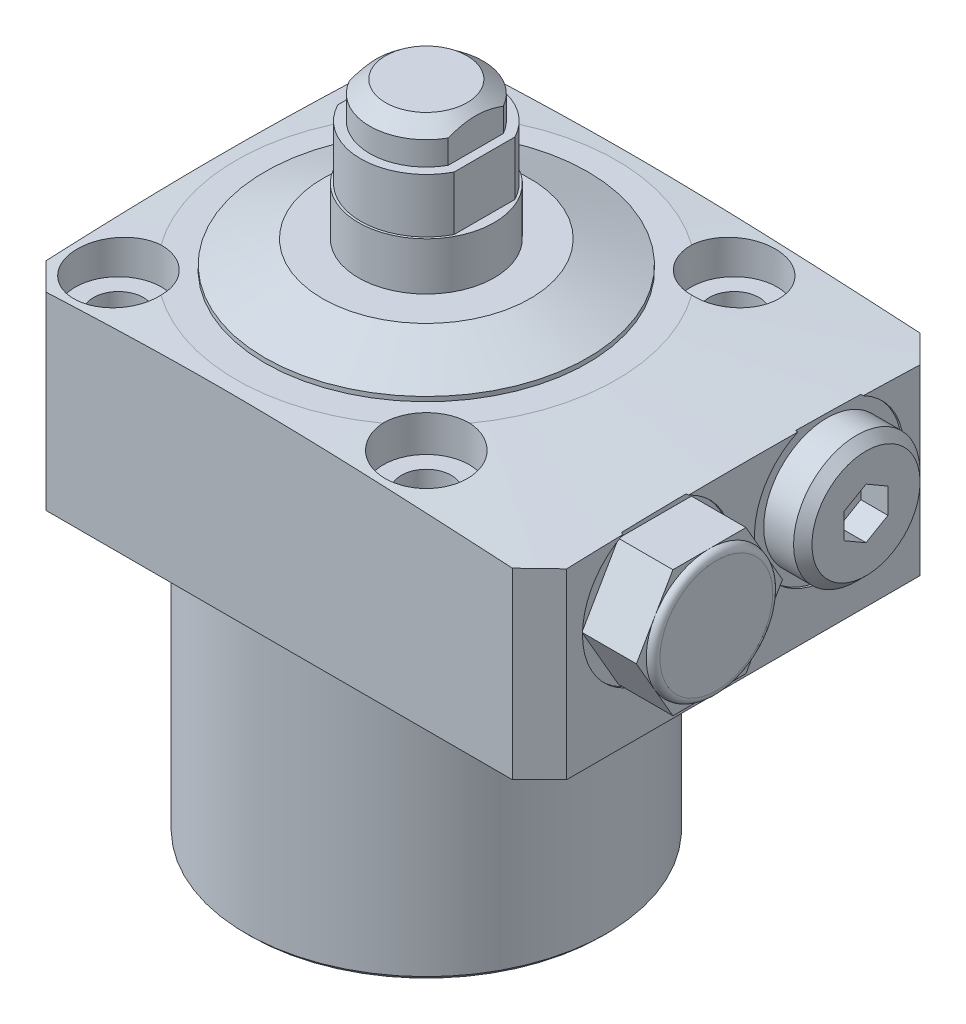
from build123d import *

# Parameters (mm, degrees)
SKETCH2_OUTSIDE_W          = 132.276
SKETCH2_OUTSIDE_H          = 132.276
SKETCH2_OUTSIDE_W_2        = 57.5
SKETCH2_OUTSIDE_H_2        = 45
CUT_EXTRUDE1_DEPTH         = 55
CHAMFER2_SIZE              = 3
CHAMFER1_SIZE              = 1.3714599
CHAMFER1_SIZE2             = 1.754126178
SKETCH5_W                  = 1.79
SKETCH5_H                  = 3.988
CUT_EXTRUDE2_DEPTH         = 23.5
CUT_EXTRUDE2_DEPTH_BACK    = 23.5
SKETCH6_W                  = 1.075
SKETCH6_H                  = 5.98
CUT_EXTRUDE3_DEPTH         = 23.5
CUT_EXTRUDE3_DEPTH_BACK    = 23.5
SKETCH10_R                 = 4.75
CUT_EXTRUDE4_DEPTH         = 4
F_5_5_5_5_DIAMETER_HOLE1_D = 5.5
CIRPATTERN1_COUNT          = 4
CUT_EXTRUDE5_DEPTH         = 3
LPATTERN1_COUNT            = 2
LPATTERN1_PITCH            = 19
SKETCH18_R                 = 1.5
LPATTERN2_COUNT            = 2
LPATTERN2_PITCH            = 19
CHAMFER3_SIZE              = 0.5
FILLET1_R                  = 0.5
BOSS_EXTRUDE2_DEPTH        = 6.78


with BuildPart() as part:
    # Sketch1 → Revolve1 (revolve)
    with BuildSketch(Plane.XY, mode=Mode.PRIVATE) as revolve1_sk:
        Polygon((-19.925, 0), (-50, 0), (-50, 19.472122454), (-21, 21.5), (0, 21.5), (0, -32.5), (-19.925, -32.5), align=None)
    revolve(revolve1_sk.sketch.rotate(Axis((0, 0, 0), (0, -1, 0)), 270), axis=Axis((0, 0, 0), (0, -1, 0)))  # turned: the seam where the file's is

    # Sketch2 outside → Cut-Extrude1 (cut, through all)
    with BuildSketch(Plane(origin=(0, 21.5, 0), x_dir=(1, 0, 0), z_dir=(0, 1, 0))):
        Rectangle(SKETCH2_OUTSIDE_W, SKETCH2_OUTSIDE_H)
        with Locations((6.25, 0)):
            Rectangle(SKETCH2_OUTSIDE_W_2, SKETCH2_OUTSIDE_H_2, mode=Mode.SUBTRACT)
    extrude(amount=-CUT_EXTRUDE1_DEPTH, mode=Mode.SUBTRACT)

    # Chamfer2
    chamfer2_edges = [part.edges().sort_by_distance(p)[0] for p in [
        (-22.5, 10.37170276, -22.5),
        (35, 10.029463905, -22.5),
        (35, 10.029463905, 22.5),
        (-22.5, 10.37170276, 22.5),
    ]]
    chamfer(chamfer2_edges, length=CHAMFER2_SIZE)

    # Sketch4 → Revolve2 (revolve)
    with BuildSketch(Plane.XY, mode=Mode.PRIVATE) as revolve2_sk:
        Polygon((0, 39.75), (-6.25, 39.75), (-6.25, 35.762), (-7.25, 35.762), (-7.25, 29.782), (-7.5, 29.782), (-7.5, 21.5), (0, 21.5), align=None)
    revolve(revolve2_sk.sketch.rotate(Axis((0, 0, 0), (0, 1, 0)), 270), axis=Axis((0, 0, 0), (0, 1, 0)))  # turned: the seam where the file's is

    # Chamfer1
    chamfer1_edges = [part.edges().sort_by_distance(p)[0] for p in [
        (0, 39.75, 6.25),
    ]]
    chamfer1_side = [part.faces().sort_by_distance(p)[0] for p in [
        (0, 37.756, 6.25),
    ]]
    chamfer(chamfer1_edges, length=CHAMFER1_SIZE, length2=CHAMFER1_SIZE2, reference=chamfer1_side[0])

    # Sketch5 → Cut-Extrude2 (cut, two sides)
    with BuildSketch(Plane.XY) as cut_extrude2_sk:
        with Locations((-6.355, 37.756)):
            Rectangle(SKETCH5_W, SKETCH5_H)
        with Locations((6.355, 37.756)):
            Rectangle(SKETCH5_W, SKETCH5_H)
    extrude(amount=CUT_EXTRUDE2_DEPTH, mode=Mode.SUBTRACT)
    extrude(cut_extrude2_sk.sketch, amount=-CUT_EXTRUDE2_DEPTH_BACK, mode=Mode.SUBTRACT)

    # Sketch6 → Cut-Extrude3 (cut, two sides)
    with BuildSketch(Plane.XY) as cut_extrude3_sk:
        with Locations((-6.9625, 32.772)):
            Rectangle(SKETCH6_W, SKETCH6_H)
        with Locations((6.9625, 32.772)):
            Rectangle(SKETCH6_W, SKETCH6_H)
    extrude(amount=CUT_EXTRUDE3_DEPTH, mode=Mode.SUBTRACT)
    extrude(cut_extrude3_sk.sketch, amount=-CUT_EXTRUDE3_DEPTH_BACK, mode=Mode.SUBTRACT)

    # Sketch10 → Cut-Extrude4 (cut)
    with BuildSketch(Plane(origin=(0, 21.5, 0), x_dir=(1, 0, 0), z_dir=(0, 1, 0))):
        with Locations(Location((-17, 17, 0), (0, 0, 269.316686409))):  # turned: the seam where the file's is
            Circle(SKETCH10_R)
    cut_extrude4 = extrude(amount=-CUT_EXTRUDE4_DEPTH, mode=Mode.SUBTRACT)

    # Ø5.5 (5.5) Diameter Hole1 (through all)
    with Locations(Plane(origin=(-17, 17.5, -17), x_dir=(0, 0, 1), z_dir=(0, 1, 0))):
        with Locations((0, 0)):
            f_5_5_5_5_diameter_hole1 = Hole(F_5_5_5_5_DIAMETER_HOLE1_D / 2)

    # CirPattern1: Cut-Extrude4, Ø5.5 (5.5) Diameter Hole1 ×4 about axis
    cirpattern1_axis = Axis((0, 0, 0), (0, 1, 0))
    add([cut_extrude4.rotate(cirpattern1_axis, i * 360 / CIRPATTERN1_COUNT) for i in range(1, CIRPATTERN1_COUNT)], mode=Mode.SUBTRACT)
    add([f_5_5_5_5_diameter_hole1.rotate(cirpattern1_axis, i * 360 / CIRPATTERN1_COUNT) for i in range(1, CIRPATTERN1_COUNT)], mode=Mode.SUBTRACT)

    # Sketch12 → Cut-Revolve2 (revolve, cut)
    with BuildSketch(Plane.XY.offset(-9.5), mode=Mode.PRIVATE) as cut_revolve2_sk:
        Polygon((35, 21.255), (34.75, 21.255), (34.75, 17.953), (34.2166, 17.4196), (24.1836, 17.4196), (21.528036408, 13), (35, 13), align=None)
    cut_revolve2 = revolve(cut_revolve2_sk.sketch.rotate(Axis((17.95729386, 13, -9.5), (1, 0, 0)), 90), axis=Axis((17.95729386, 13, -9.5), (1, 0, 0)), mode=Mode.SUBTRACT)  # turned: the seam where the file's is

    # Sketch13 → Revolve3 (revolve)
    with BuildSketch(Plane.XY.offset(-9.5), mode=Mode.PRIVATE) as revolve3_sk:
        Polygon((34.75, 19.985), (38.045, 19.985), (39.06, 18.97), (39.06, 13), (34.75, 13), align=None)
    revolve(revolve3_sk.sketch.rotate(Axis((10.466346838, 13, -9.5), (1, 0, 0)), 90), axis=Axis((10.466346838, 13, -9.5), (1, 0, 0)))  # turned: the seam where the file's is

    # Sketch14 → Cut-Extrude5 (cut)
    with BuildSketch(Plane(origin=(39.06, 0, 0), x_dir=(0, 0, -1), z_dir=(1, 0, 0))):
        Polygon((11.9255, 11.599636922), (11.9255, 14.400363078), (9.5, 15.800726156), (7.0745, 14.400363078), (7.0745, 11.599636922), (9.5, 10.199273844), align=None)
    cut_extrude5 = extrude(amount=-CUT_EXTRUDE5_DEPTH, mode=Mode.SUBTRACT)

    # Sketch16 → Cut-Revolve4 (revolve, cut)
    with BuildSketch(Plane(origin=(9.5, 0, -9.5), x_dir=(-1, 0, 0), z_dir=(0, 0, -1)), mode=Mode.PRIVATE) as cut_revolve4_sk:
        Polygon((-17.5, 13.502151548), (-20, 12), (-20, 2.875), (-20.625, 2.25), (-22.5, 2.25), (-22.5, 0), (-17.5, 0), align=None)
    cut_revolve4 = revolve(cut_revolve4_sk.sketch.rotate(Axis((27, -1.224048676, -9.5), (0, -1, 0)), 180), axis=Axis((27, -1.224048676, -9.5), (0, -1, 0)), mode=Mode.SUBTRACT)  # turned: the seam where the file's is

    # LPattern1: Cut-Revolve2, Cut-Extrude5, Cut-Revolve4 ×2
    with Locations(*[(0, 0, i * LPATTERN1_PITCH) for i in range(1, LPATTERN1_COUNT)]):
        add(cut_revolve2, mode=Mode.SUBTRACT)
        add(cut_extrude5, mode=Mode.SUBTRACT)
        add(cut_revolve4, mode=Mode.SUBTRACT)

    # Chamfer3
    chamfer3_edges = [part.edges().sort_by_distance(p)[0] for p in [
        (0, -32.5, -19.925),
    ]]
    chamfer(chamfer3_edges, length=CHAMFER3_SIZE)

    # Fillet1
    fillet1_edges = [part.edges().sort_by_distance(p)[0] for p in [
        (0, 0, -19.925),
    ]]
    fillet(fillet1_edges, radius=FILLET1_R)

    # Sketch19 → Revolve5 (revolve)
    with BuildSketch(Plane.XY, mode=Mode.PRIVATE) as revolve5_sk:
        Polygon((7.5, 21.5), (17.82, 21.5), (17.82, 22), (11.473380261, 24.5), (7.5, 24.5), align=None)
    revolve(revolve5_sk.sketch.rotate(Axis((0, 29.782, 0), (0, -1, 0)), 270), axis=Axis((0, 29.782, 0), (0, -1, 0)))  # turned: the seam where the file's is

    # Sketch20 → Boss-Extrude2 (add)
    with BuildSketch(Plane(origin=(34.75, 0, 0), x_dir=(0, 0, -1), z_dir=(1, 0, 0))):
        Polygon((-1.434416739, 13), (-5.46720837, 19.985), (-13.53279163, 19.985), (-17.565583261, 13), (-13.53279163, 6.015), (-5.46720837, 6.015), align=None)
    extrude(amount=BOSS_EXTRUDE2_DEPTH)

    # Sketch21 → Cut-Revolve5 (revolve, cut)
    with BuildSketch(Plane(origin=(0, 0, 9.5), x_dir=(-1, 0, 0), z_dir=(0, 0, -1)), mode=Mode.PRIVATE) as cut_revolve5_sk:
        with BuildLine():
            Line((-40.768, 22.90757935), (-43.889027629, 22.90757935))
            Line((-43.889027629, 22.90757935), (-43.889027629, 19.223))
            Line((-43.889027629, 19.223), (-41.53, 19.223))
            ThreePointArc((-41.53, 19.223), (-41.306815367, 19.761815367), (-40.768, 19.985))
            Line((-40.768, 19.985), (-40.768, 22.90757935))
        make_face()
    revolve(cut_revolve5_sk.sketch.rotate(Axis((17.95729386, 13, 9.5), (-1, 0, 0)), 270), axis=Axis((17.95729386, 13, 9.5), (-1, 0, 0)), mode=Mode.SUBTRACT)  # turned: the seam where the file's is


with BuildPart() as body_2:
    # Sketch18 → Revolve4 (revolve)
    with BuildSketch(Plane(origin=(-9.5, 0, -9.5), x_dir=(1, 0, 0), z_dir=(0, 0, 1))):
        with Locations((33.001, 0.74999)):
            Circle(SKETCH18_R)
    revolve(axis=Axis((27, -2.585671099, -9.5), (0, -1, 0)))


with BuildPart() as lpattern2_1:
    # LPattern2: pattern copy
    add(body_2.part.moved(Location(Vector(0, 0, 1) * (1 * LPATTERN2_PITCH))))


solid = Compound([part.part, body_2.part, lpattern2_1.part])
